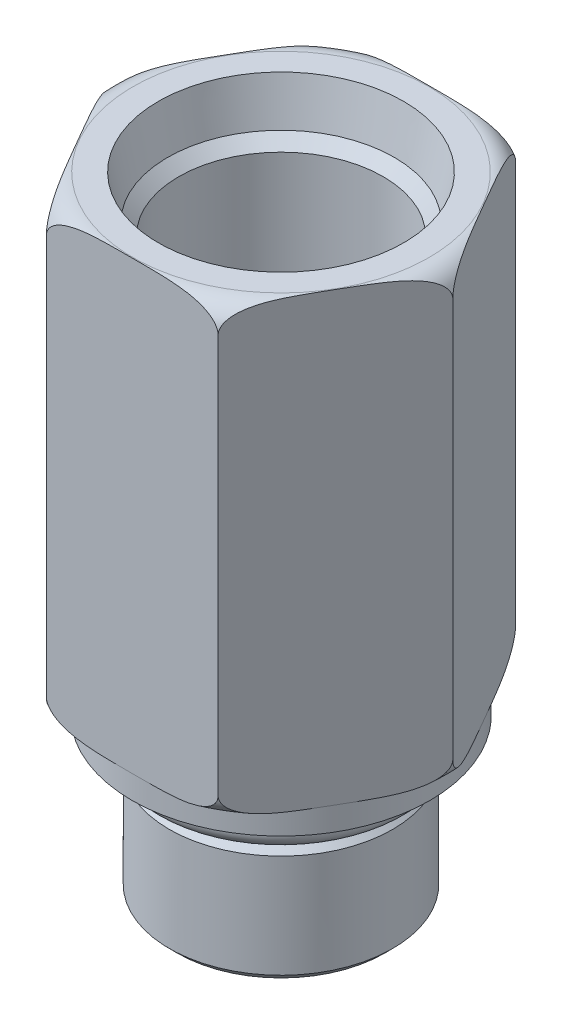
from build123d import *

# Parameters (mm, degrees)
EXTRUDE1_DEPTH     = 28.575
CHAMFER1_SIZE      = 0.508
SKETCH7_R          = 0.9906
CUT_EXTRUDE1_DEPTH = 9.906


with BuildPart() as part:
    # Sketch1 → Extrude1 (new body)
    with BuildSketch(Plane(origin=(0, 0, 0), x_dir=(1, 0, 0), z_dir=(0, 1, 0))):
        Polygon((10.998522628, 0), (5.499261314, 9.525), (-5.499261314, 9.525), (-10.998522628, 0), (-5.499261314, -9.525), (5.499261314, -9.525), align=None)
    extrude(amount=EXTRUDE1_DEPTH)

    # Sketch2 → Cut-Revolve1 (revolve, cut)
    with BuildSketch(Plane.XY, mode=Mode.PRIVATE) as cut_revolve1_sk:
        with BuildLine():
            Line((10.998522628, 28.575), (9.474522628, 28.575))
            ThreePointArc((9.474522628, 28.575), (10.552153363, 28.128630735), (10.998522628, 27.051))
            Line((10.998522628, 27.051), (10.998522628, 28.575))
        make_face()
    revolve(cut_revolve1_sk.sketch.rotate(Axis((0, 26.9748, 0), (0, 1, 0)), 90), axis=Axis((0, 26.9748, 0), (0, 1, 0)), mode=Mode.SUBTRACT)  # turned: the seam where the file's is

    # Sketch3 → Cut-Revolve2 (revolve, cut)
    with BuildSketch(Plane.XY, mode=Mode.PRIVATE) as cut_revolve2_sk:
        with BuildLine():
            Line((10.998522628, 0), (9.474522628, 0))
            ThreePointArc((9.474522628, 0), (10.552153363, 0.446369265), (10.998522628, 1.524))
            Line((10.998522628, 1.524), (10.998522628, 0))
        make_face()
    revolve(cut_revolve2_sk.sketch.rotate(Axis((0, -0.0762, 0), (0, 1, 0)), 90), axis=Axis((0, -0.0762, 0), (0, 1, 0)), mode=Mode.SUBTRACT)  # turned: the seam where the file's is

    # S2D0004 → Cut-Revolve3 (revolve, cut)
    with BuildSketch(Plane(origin=(0, 28.575, 0), x_dir=(1, 0, 0), z_dir=(0, 0, 1)), mode=Mode.PRIVATE) as cut_revolve3_sk:
        Polygon((0, 0), (7.8486, 0), (7.252017498, -2.8067), (6.5405, -3.518217498), (6.5405, -12.446), (0, -12.446), align=None)
    revolve(cut_revolve3_sk.sketch.rotate(Axis((0, 0, 0), (0, 1, 0)), 90), axis=Axis((0, 0, 0), (0, 1, 0)), mode=Mode.SUBTRACT)  # turned: the seam where the file's is

    # Sketch5 → Revolve1 (revolve)
    with BuildSketch(Plane.XY, mode=Mode.PRIVATE) as revolve1_sk:
        Polygon((0, 0), (9.525, 0), (9.525, -1.4986), (6.096, -1.4986), (6.096, -3.7846), (7.14375, -3.7846), (7.14375, -11.4046), (0, -11.4046), align=None)
    revolve(revolve1_sk.sketch.rotate(Axis((0, -14.936765322, 0), (0, 1, 0)), 90), axis=Axis((0, -14.936765322, 0), (0, 1, 0)))  # turned: the seam where the file's is

    # Chamfer1
    chamfer1_edges = [part.edges().sort_by_distance(p)[0] for p in [
        (0, -3.7846, 7.14375),
        (0, -11.4046, 7.14375),
    ]]
    chamfer(chamfer1_edges, length=CHAMFER1_SIZE)

    # Sketch8 → Cut-Extrude1 (cut)
    with BuildSketch(Plane.XZ.offset(11.4046)):
        Polygon((3.666174209, 0), (1.833087105, 3.175), (-1.833087105, 3.175), (-3.666174209, 0), (-1.833087105, -3.175), (1.833087105, -3.175), align=None)
    extrude(amount=-CUT_EXTRUDE1_DEPTH, mode=Mode.SUBTRACT)


with BuildPart() as body_2:
    # Sketch7 → Revolve3 (revolve)
    with BuildSketch(Plane.XY, mode=Mode.PRIVATE) as revolve3_sk:
        with Locations((7.0866, -2.4892)):
            Circle(SKETCH7_R)
    revolve(revolve3_sk.sketch.rotate(Axis((0, -3.08864, 0), (0, 1, 0)), 90), axis=Axis((0, -3.08864, 0), (0, 1, 0)))  # turned: the seam where the file's is


solid = Compound([part.part, body_2.part])
